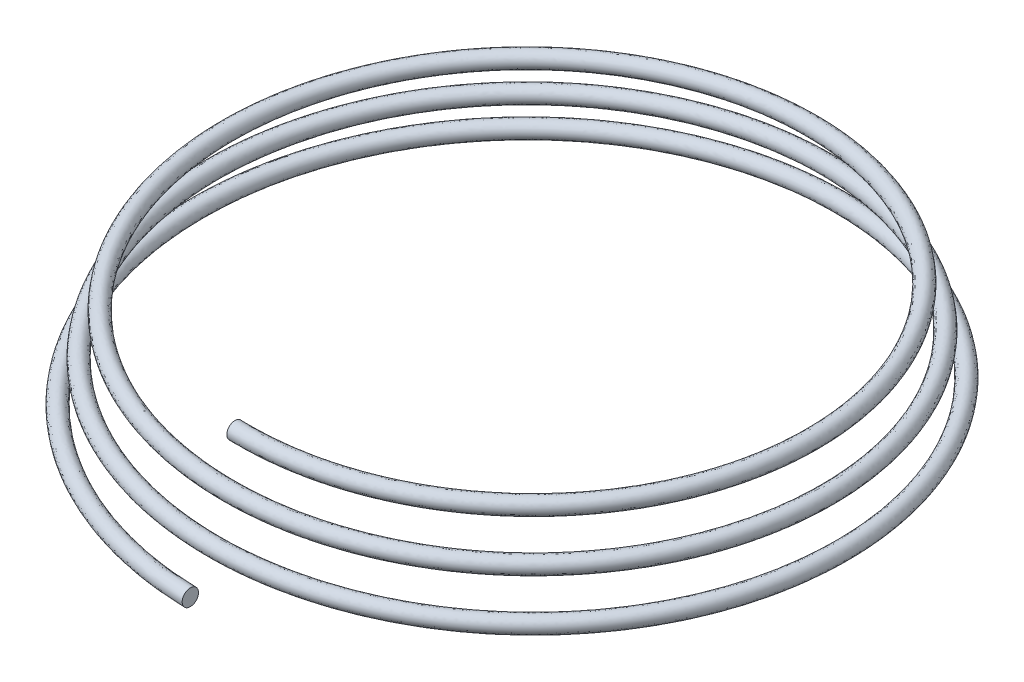
from build123d import *

# Parameters (mm, degrees)
SKETCH_3_R = 0.1


with BuildPart() as part:
    # 扫描1: sweep along a curve in space
    with BuildLine() as sweep_1_path:
        add(Edge.make_bspline(
            [(0, 0, 4), (-0.392699082, 0.0078125, 3.997156483), (-0.784499682, 0.015625, 3.936070607), (-1.532825159, 0.03125, 3.70312562), (-1.889257397, 0.0390625, 3.531298314), (-2.536347183, 0.0546875, 3.092087004), (-2.826925488, 0.0625, 2.824760211), (-3.317592902, 0.078125, 2.217915712), (-3.517622921, 0.0859375, 1.878475595), (-3.810363717, 0.1015625, 1.156875855), (-3.903040553, 0.109375, 0.77480744), (-3.973542506, 0.125, 0.000968279), (-3.951361639, 0.1328125, -0.39070554), (-3.794520921, 0.1484375, -1.150046297), (-3.659883439, 0.15625, -1.517618951), (-3.290160818, 0.171875, -2.1972571), (-3.055124357, 0.1796875, -2.509239051), (-2.50521771, 0.1953125, -3.051103016), (-2.190418209, 0.203125, -3.28091936), (-1.508372744, 0.21875, -3.639031795), (-1.141213298, 0.2265625, -3.767285662), (-0.386224714, 0.2421875, -3.911663778), (0.001509578, 0.25, -3.927772776), (0.764232457, 0.265625, -3.846936578), (1.139126063, 0.2734375, -3.750004298), (1.843993371, 0.2890625, -3.451883097), (2.173880124, 0.296875, -3.250734029), (2.760561296, 0.3125, -2.761900238), (3.017284241, 0.3203125, -2.474278759), (3.435871596, 0.3359375, -1.837582119), (3.597686085, 0.34375, -1.488588052), (3.812939712, 0.359375, -0.759400707), (3.86635468, 0.3671875, -0.379299321), (3.860667645, 0.3828125, 0.379299321), (3.801569188, 0.390625, 0.757701835), (3.57640369, 0.40625, 1.480381769), (3.410367485, 0.4140625, 1.824569755), (2.986045191, 0.4296875, 2.449376554), (2.727814454, 0.4375, 2.729918908), (2.141686264, 0.453125, 3.203584885), (1.813863814, 0.4609375, 3.396651543), (1.117023603, 0.4765625, 3.679136607), (0.748093957, 0.484375, 3.768522353), (0.000925271, 0.5, 3.836397493), (-0.377220177, 0.5078125, 3.814881233), (-1.110276358, 0.5234375, 3.663268842), (-1.465096091, 0.53125, 3.533194427), (-2.121099174, 0.546875, 3.176105013), (-2.422201929, 0.5546875, 2.949137113), (-2.945115772, 0.5703125, 2.418180589), (-3.166863555, 0.578125, 2.114260283), (-3.512342784, 0.59375, 1.455849884), (-3.636033582, 0.6015625, 1.101443359), (-3.775183371, 0.6171875, 0.37273935), (-3.790627763, 0.625, -0.001466569), (-3.712418377, 0.640625, -0.737518975), (-3.618777188, 0.6484375, -1.09927381), (-3.330911719, 0.6640625, -1.779381589), (-3.136726013, 0.671875, -2.097650677), (-2.664893658, 0.6875, -2.663615539), (-2.38730813, 0.6953125, -2.911242428), (-1.772894477, 0.7109375, -3.314940767), (-1.436144663, 0.71875, -3.470964155), (-0.73260286, 0.734375, -3.678438292), (-0.365899561, 0.7421875, -3.729865842), (0.365899561, 0.7578125, -3.724178807), (0.730903988, 0.765625, -3.667067768), (1.42793838, 0.78125, -3.449681761), (1.759882113, 0.7890625, -3.289436656), (2.362405925, 0.8046875, -2.880003378), (2.632912327, 0.8125, -2.630868697), (3.089576869, 0.828125, -2.065456817), (3.275680166, 0.8359375, -1.749252033), (3.547909497, 0.8515625, -1.07717135), (3.634004152, 0.859375, -0.721380475), (3.69925248, 0.875, -0.000882262), (3.678400826, 0.8828125, 0.363734813), (3.532016762, 0.8984375, 1.070506419), (3.406505415, 0.90625, 1.412573232), (3.062049208, 0.921875, 2.044941248), (2.843149868, 0.9296875, 2.335164808), (2.331143467, 0.9453125, 2.839128527), (2.038102357, 0.953125, 3.05280775), (1.403327025, 0.96875, 3.385653772), (1.06167342, 0.9765625, 3.504781503), (0.359253987, 0.9921875, 3.638702964), (-0.00142356, 1, 3.65348275), (-0.710805492, 1.015625, 3.577900176), (-1.059421558, 1.0234375, 3.487550078), (-1.714769808, 1.0390625, 3.209940342), (-2.021421229, 1.046875, 3.022717996), (-2.566669782, 1.0625, 2.567887077), (-2.805200615, 1.0703125, 2.300337501), (-3.194009938, 1.0859375, 1.708206835), (-3.344242226, 1.09375, 1.383701273), (-3.543936873, 1.109375, 0.705805013), (-3.593377004, 1.1171875, 0.352499801), (-3.587689969, 1.1328125, -0.352499801), (-3.532566349, 1.140625, -0.704106141), (-3.322959832, 1.15625, -1.375494991), (-3.168505827, 1.1640625, -1.695194471), (-2.773961565, 1.1796875, -2.275435296), (-2.53392294, 1.1875, -2.535905747), (-1.98922737, 1.203125, -2.975568853), (-1.684640251, 1.2109375, -3.154708788), (-1.037319097, 1.2265625, -3.416682388), (-0.694666993, 1.234375, -3.499485951), (-0.000839253, 1.25, -3.562107467), (0.35024945, 1.2578125, -3.54192042), (1.03073648, 1.2734375, -3.400764683), (1.360050373, 1.28125, -3.279816404), (1.968783321, 1.296875, -2.947993403), (2.248127687, 1.3046875, -2.737162624), (2.733141283, 1.3203125, -2.244106346), (2.938751944, 1.328125, -1.96194443), (3.25896476, 1.34375, -1.350804166), (3.373529423, 1.3515625, -1.021903481), (3.502222558, 1.3671875, -0.345768623), (3.516337737, 1.375, 0.001380552), (3.443381976, 1.390625, 0.68409201), (3.356322968, 1.3984375, 1.019569305), (3.088968965, 1.4140625, 1.650158027), (2.90870998, 1.421875, 1.945191782), (2.470880497, 1.4375, 2.469724025), (2.213366872, 1.4453125, 2.699158801), (1.643519193, 1.4609375, 3.073079109), (1.331257884, 1.46875, 3.217520297), (0.679007165, 1.484375, 3.409435454), (0.33910004, 1.4921875, 3.456888166), (0, 1.5, 3.454044649)],
            knots=[0, 0, 0, 0, 0.015625, 0.015625, 0.03125, 0.03125, 0.046875, 0.046875, 0.0625, 0.0625, 0.078125, 0.078125, 0.09375, 0.09375, 0.109375, 0.109375, 0.125, 0.125, 0.140625, 0.140625, 0.15625, 0.15625, 0.171875, 0.171875, 0.1875, 0.1875, 0.203125, 0.203125, 0.21875, 0.21875, 0.234375, 0.234375, 0.25, 0.25, 0.265625, 0.265625, 0.28125, 0.28125, 0.296875, 0.296875, 0.3125, 0.3125, 0.328125, 0.328125, 0.34375, 0.34375, 0.359375, 0.359375, 0.375, 0.375, 0.390625, 0.390625, 0.40625, 0.40625, 0.421875, 0.421875, 0.4375, 0.4375, 0.453125, 0.453125, 0.46875, 0.46875, 0.484375, 0.484375, 0.5, 0.5, 0.515625, 0.515625, 0.53125, 0.53125, 0.546875, 0.546875, 0.5625, 0.5625, 0.578125, 0.578125, 0.59375, 0.59375, 0.609375, 0.609375, 0.625, 0.625, 0.640625, 0.640625, 0.65625, 0.65625, 0.671875, 0.671875, 0.6875, 0.6875, 0.703125, 0.703125, 0.71875, 0.71875, 0.734375, 0.734375, 0.75, 0.75, 0.765625, 0.765625, 0.78125, 0.78125, 0.796875, 0.796875, 0.8125, 0.8125, 0.828125, 0.828125, 0.84375, 0.84375, 0.859375, 0.859375, 0.875, 0.875, 0.890625, 0.890625, 0.90625, 0.90625, 0.921875, 0.921875, 0.9375, 0.9375, 0.953125, 0.953125, 0.96875, 0.96875, 0.984375, 0.984375, 1, 1, 1, 1], degree=3))
    # 草图3 → 扫描1 (sweep)
    with BuildSketch(Plane(origin=(0, 0, 0), x_dir=(0, 0, -1), z_dir=(1, 0, 0))):
        with Locations((-4, 0)):
            Circle(SKETCH_3_R)
    sweep(path=sweep_1_path.line, is_frenet=True)


solid = part.part
